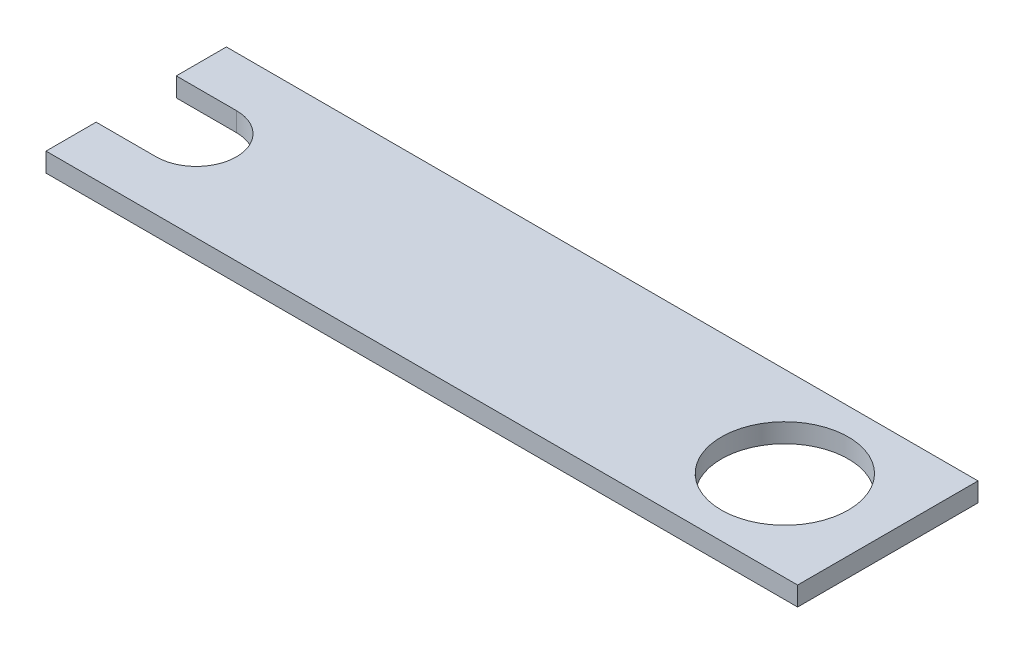
from build123d import *

# Parameters (mm, degrees)
SKETCH1_R           = 21.1
BOSS_EXTRUDE1_DEPTH = 6.35


with BuildPart() as part:
    # Sketch1 → Boss-Extrude1 (new body)
    with BuildSketch(Plane(origin=(0, 0, 0), x_dir=(1, 0, 0), z_dir=(0, 1, 0))):
        with BuildLine():
            Line((-195.75, 13.33), (-215.75, 13.33))
            Line((-215.75, 13.33), (-215.75, 30))
            Line((-215.75, 30), (34.25, 30))
            Line((34.25, 30), (34.25, -30))
            Line((34.25, -30), (-215.75, -30))
            Line((-215.75, -30), (-215.75, -13.33))
            Line((-215.75, -13.33), (-195.75, -13.33))
            ThreePointArc((-195.75, -13.33), (-182.42, 0), (-195.75, 13.33))
        make_face()
        Circle(SKETCH1_R, mode=Mode.SUBTRACT)
    extrude(amount=BOSS_EXTRUDE1_DEPTH)


solid = part.part
